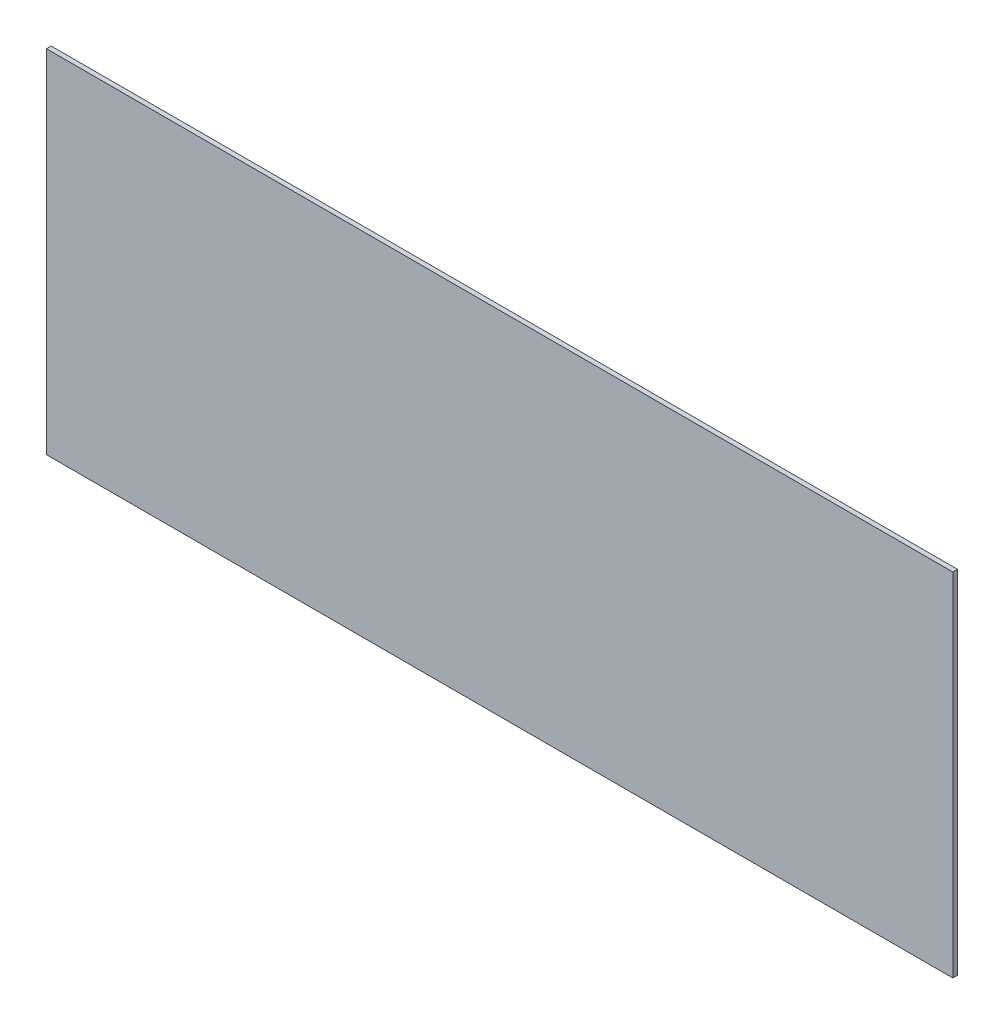
from build123d import *

# Parameters (mm, degrees)
SKETCH_1_W      = 290
SKETCH_1_H      = 112.5
EXTRUDE_1_DEPTH = 1.5


with BuildPart() as part:
    # 草圖1 → 填料-伸長1 (new body)
    with BuildSketch(Plane.XY):
        with Locations((-6.64721959, 8.659747292)):
            Rectangle(SKETCH_1_W, SKETCH_1_H)
    extrude(amount=EXTRUDE_1_DEPTH)


solid = part.part
